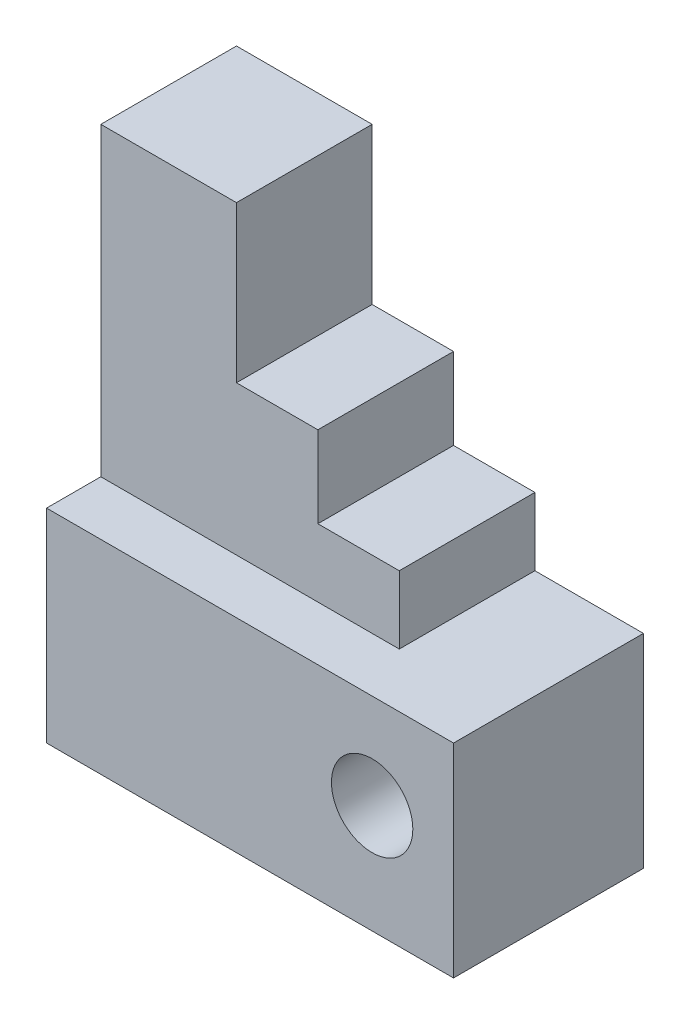
from build123d import *

# Parameters (mm, degrees)
BOSS_EXTRUDE1_DEPTH = 20
SKETCH2_W           = 60
SKETCH2_H           = 30
BOSS_EXTRUDE2_DEPTH = 28
SKETCH3_R           = 6
CUT_EXTRUDE1_DEPTH  = 28


with BuildPart() as part:
    # Sketch1 → Boss-Extrude1 (new body)
    with BuildSketch(Plane.XY):
        Polygon((0, 75), (0, 30), (44, 30), (44, 40), (32, 40), (32, 52), (20, 52), (20, 75), align=None)
    extrude(amount=BOSS_EXTRUDE1_DEPTH)

    # Sketch2 → Boss-Extrude2 (add)
    with BuildSketch(Plane(origin=(0, 0, 0), x_dir=(-1, 0, 0), z_dir=(0, 0, -1))):
        with Locations((-30, 15)):
            Rectangle(SKETCH2_W, SKETCH2_H)
    extrude(amount=-BOSS_EXTRUDE2_DEPTH)

    # Sketch3 → Cut-Extrude1 (cut)
    with BuildSketch(Plane.XY.offset(28)):
        with Locations((48, 16)):
            Circle(SKETCH3_R)
    extrude(amount=-CUT_EXTRUDE1_DEPTH, mode=Mode.SUBTRACT)


solid = part.part
